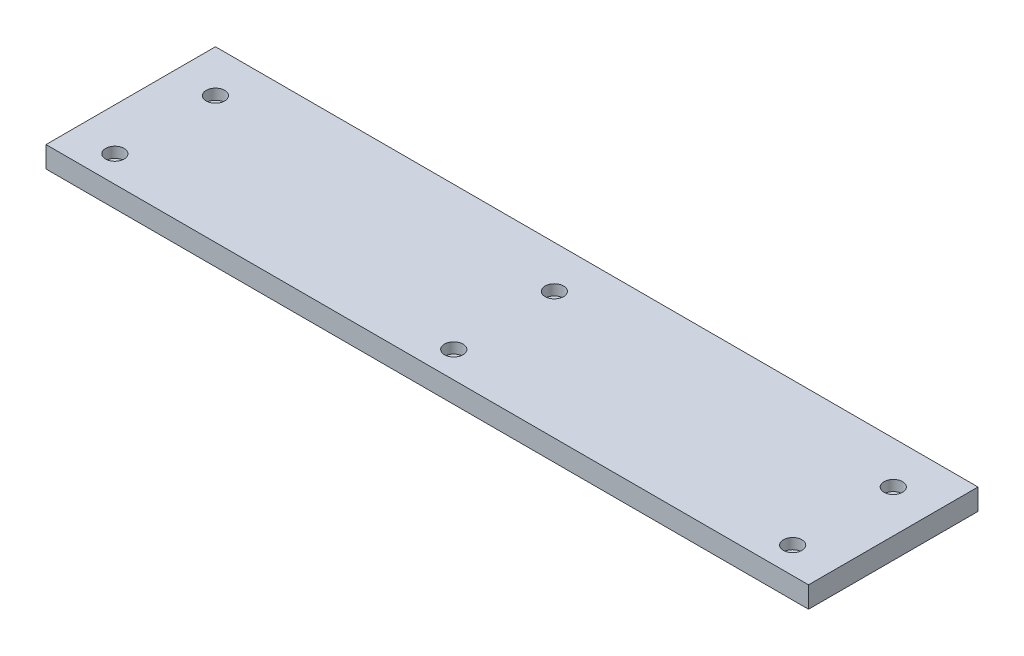
from build123d import *

# Parameters (mm, degrees)
SKETCH1_W                                        = 457.2
SKETCH1_H                                        = 101.6
BOSS_EXTRUDE1_DEPTH                              = 12.7
CBORE_FOR_1_4_SOCKET_HEAD_CAP_SCREW1_D           = 6.7564
CBORE_FOR_1_4_SOCKET_HEAD_CAP_SCREW1_DEPTH       = 14.480172657
CBORE_FOR_1_4_SOCKET_HEAD_CAP_SCREW1_CBORE_D     = 11.1125
CBORE_FOR_1_4_SOCKET_HEAD_CAP_SCREW1_CBORE_DEPTH = 6.35
CBORE_FOR_1_4_SOCKET_HEAD_CAP_SCREW1_TIP         = 2.029827343


with BuildPart() as part:
    # Sketch1 → Boss-Extrude1 (new body)
    with BuildSketch(Plane(origin=(0, 0, 0), x_dir=(1, 0, 0), z_dir=(0, 1, 0))):
        Rectangle(SKETCH1_W, SKETCH1_H)
    extrude(amount=-BOSS_EXTRUDE1_DEPTH)

    # CBORE for 1/4 Socket Head Cap Screw1
    with Locations(Plane(origin=(0, 0, 0), x_dir=(1, 0, 0), z_dir=(0, 1, 0))):
        with Locations((-203.2, 25.4), (-203.2, -34.925), (0, -34.925), (0, 25.4), (203.2, 25.4), (203.2, -34.925)):
            CounterBoreHole(CBORE_FOR_1_4_SOCKET_HEAD_CAP_SCREW1_D / 2, CBORE_FOR_1_4_SOCKET_HEAD_CAP_SCREW1_CBORE_D / 2, CBORE_FOR_1_4_SOCKET_HEAD_CAP_SCREW1_CBORE_DEPTH, depth=CBORE_FOR_1_4_SOCKET_HEAD_CAP_SCREW1_DEPTH)
            with Locations((0, 0, -(CBORE_FOR_1_4_SOCKET_HEAD_CAP_SCREW1_DEPTH + CBORE_FOR_1_4_SOCKET_HEAD_CAP_SCREW1_TIP / 2))):  # 118° drill point
                Cone(0, CBORE_FOR_1_4_SOCKET_HEAD_CAP_SCREW1_D / 2, CBORE_FOR_1_4_SOCKET_HEAD_CAP_SCREW1_TIP, mode=Mode.SUBTRACT)


solid = part.part
